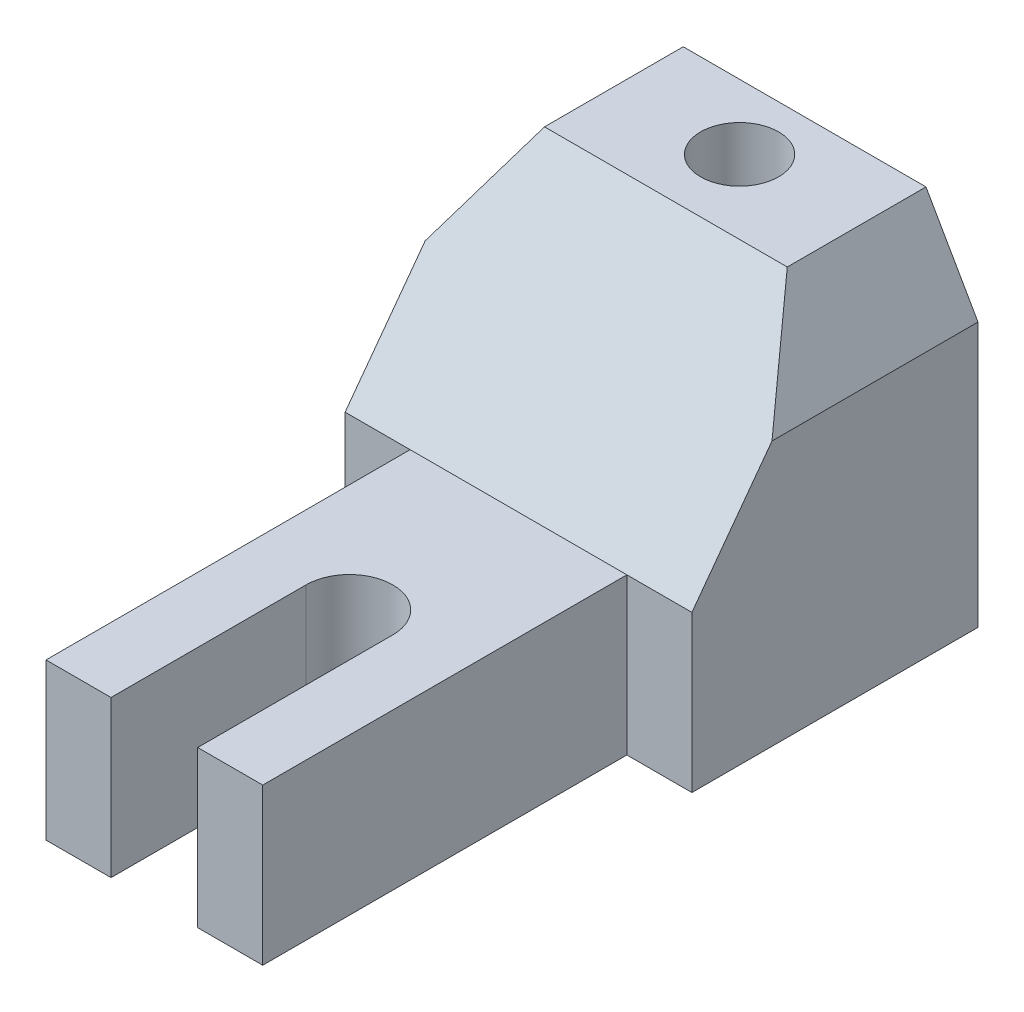
from build123d import *

# Parameters (mm, degrees)
CROQUIS1_W              = 80
CROQUIS1_H              = 150
SALIENTE_EXTRUIR1_DEPTH = 82
CORTAR_EXTRUIR1_DEPTH   = 150
CROQUIS3_R              = 9
CROQUIS3_W              = 12
CROQUIS3_H              = 84
CROQUIS3_W_2            = 3
CORTAR_EXTRUIR2_DEPTH   = 150
CORTAR_EXTRUIR3_DEPTH   = 80


with BuildPart() as part:
    # Croquis1 → Saliente-Extruir1 (new body)
    with BuildSketch(Plane(origin=(0, 0, 0), x_dir=(1, 0, 0), z_dir=(0, 1, 0))):
        with Locations((58.762376238, 47.339108911)):
            Rectangle(CROQUIS1_W, CROQUIS1_H)
    extrude(amount=SALIENTE_EXTRUIR1_DEPTH)

    # Croquis2 → Cortar-Extruir1 (cut)
    with BuildSketch(Plane(origin=(0, 0, -122.339108911), x_dir=(-1, 0, 0), z_dir=(0, 0, -1))):
        Polygon((-98.762376238, 82), (-98.762376238, 61), (-86.762376238, 82), align=None)
        Polygon((-18.762376238, 82), (-30.762376238, 82), (-18.762376238, 61), align=None)
    extrude(amount=-CORTAR_EXTRUIR1_DEPTH, mode=Mode.SUBTRACT)

    # Croquis3 → Cortar-Extruir2 (cut)
    with BuildSketch(Plane(origin=(0, 82, 0), x_dir=(1, 0, 0), z_dir=(0, 1, 0))):
        with Locations((58.762376238, 107.339108911)):
            Circle(CROQUIS3_R)
        with BuildLine():
            ThreePointArc((68.762376238, 17.339108911), (58.762376238, 27.339108911), (48.762376238, 17.339108911))
            Line((48.762376238, 17.339108911), (48.762376238, -27.660891089))
            Line((48.762376238, -27.660891089), (68.762376238, -27.660891089))
            Line((68.762376238, -27.660891089), (68.762376238, 17.339108911))
        make_face()
        with Locations((24.762376238, 14.339108911)):
            Rectangle(CROQUIS3_W, CROQUIS3_H)
        with Locations((32.262376238, 14.339108911)):
            Rectangle(CROQUIS3_W_2, CROQUIS3_H)
        with Locations((92.762376238, 14.339108911)):
            Rectangle(CROQUIS3_W, CROQUIS3_H)
        with Locations((85.262376238, 14.339108911)):
            Rectangle(CROQUIS3_W_2, CROQUIS3_H)
    extrude(amount=-CORTAR_EXTRUIR2_DEPTH, mode=Mode.SUBTRACT)

    # Croquis4 → Cortar-Extruir3 (cut)
    with BuildSketch(Plane(origin=(98.762376238, 0, 0), x_dir=(0, 0, -1), z_dir=(1, 0, 0))):
        Polygon((-27.660891089, 36), (56.339108911, 36), (90.339108911, 82), (-27.660891089, 82), align=None)
    extrude(amount=-CORTAR_EXTRUIR3_DEPTH, mode=Mode.SUBTRACT)


solid = part.part
